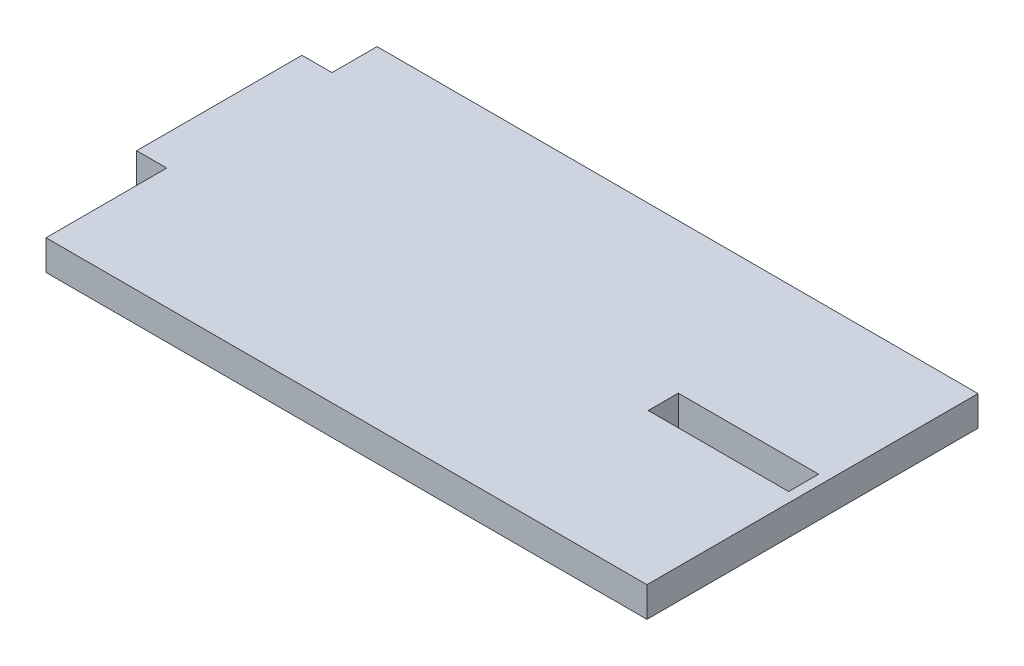
from build123d import *

# Parameters (mm, degrees)
SKETCH2_W           = 18.688991821
SKETCH2_H           = 4
BOSS_EXTRUDE1_DEPTH = 4


with BuildPart() as part:
    # Sketch2 → Boss-Extrude1 (new body)
    with BuildSketch(Plane(origin=(0, 0, 0), x_dir=(1, 0, 0), z_dir=(0, 1, 0))):
        Polygon((0, -6), (-4, -6), (-4, -28), (0, -28), (0, -44.07), (80, -44.07), (80, 0), (0, 0), align=None)
        with Locations((69.344495911, -21.9)):
            Rectangle(SKETCH2_W, SKETCH2_H, mode=Mode.SUBTRACT)
    extrude(amount=BOSS_EXTRUDE1_DEPTH)


solid = part.part
